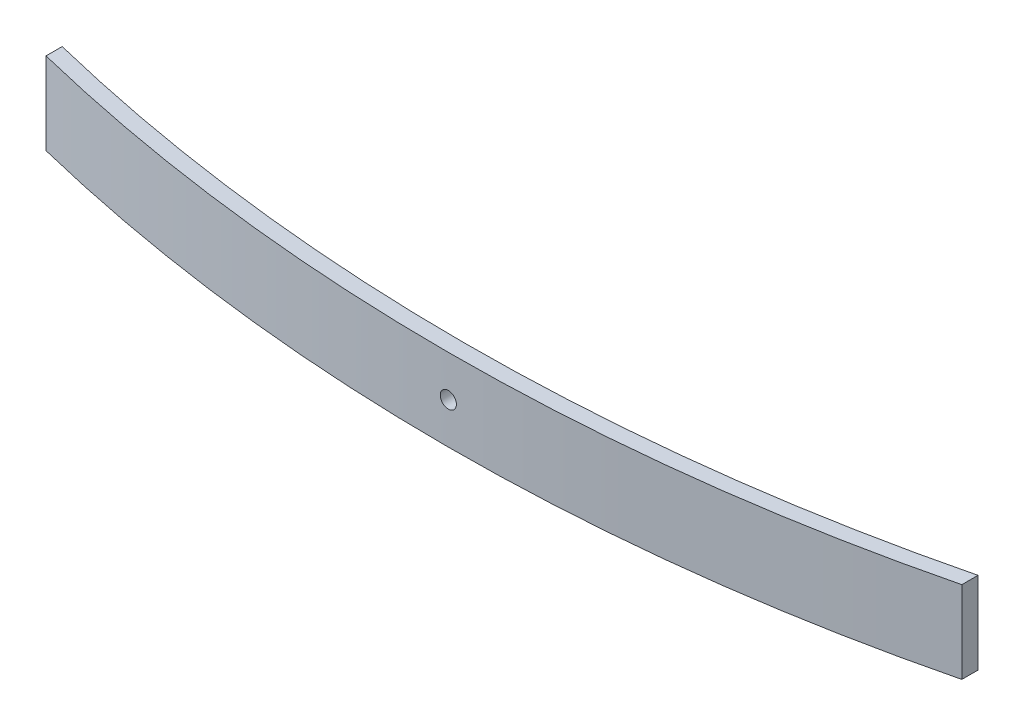
from build123d import *

# Parameters (mm, degrees)
BOSS_EXTRUDE1_DEPTH = 76.2
SKETCH10_R          = 7.5
CUT_EXTRUDE1_DEPTH  = 224


with BuildPart() as part:
    # Sketch1 → Boss-Extrude1 (new body)
    with BuildSketch(Plane(origin=(0, 0, 0), x_dir=(1, 0, 0), z_dir=(0, 1, 0))):
        with BuildLine():
            ThreePointArc((425.021699517, -156.394883177), (0, -208), (-425.021699517, -156.394883177))
            Line((-425.021699517, -156.394883177), (-425.021699517, -171.394883177))
            ThreePointArc((-425.021699517, -171.394883177), (0, -223), (425.021699517, -171.394883177))
            Line((425.021699517, -171.394883177), (425.021699517, -156.394883177))
        make_face()
    extrude(amount=BOSS_EXTRUDE1_DEPTH)

    # Sketch10 → Cut-Extrude1 (cut, through all)
    with BuildSketch(Plane.XY):
        with Locations((0, 38.1)):
            Circle(SKETCH10_R)
    extrude(amount=CUT_EXTRUDE1_DEPTH, mode=Mode.SUBTRACT)


solid = part.part
